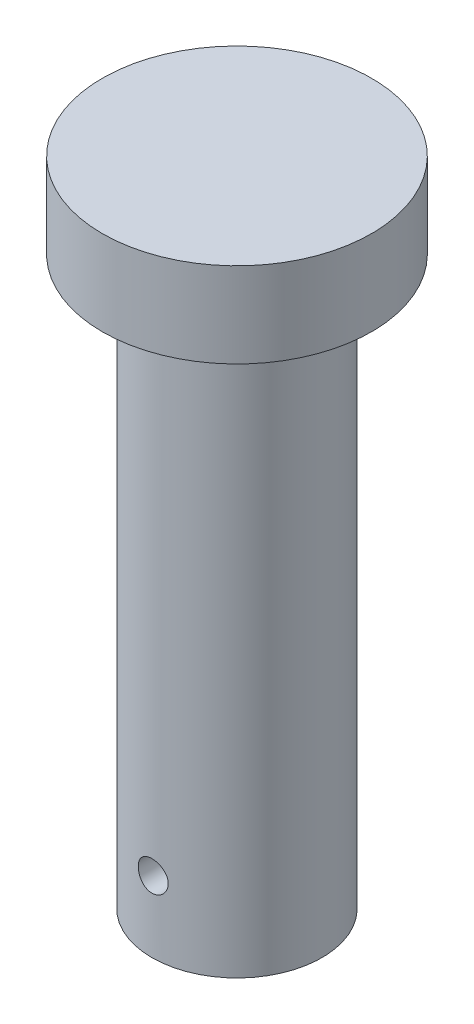
from build123d import *

# Parameters (mm, degrees)
SKETCH1_R           = 19
BOSS_EXTRUDE1_DEPTH = 12
SKETCH2_R           = 12
BOSS_EXTRUDE2_DEPTH = 80


with BuildPart() as part:
    # Sketch1 → Boss-Extrude1 (new body)
    with BuildSketch(Plane(origin=(0, 0, 0), x_dir=(1, 0, 0), z_dir=(0, 1, 0))):
        Circle(SKETCH1_R)
    extrude(amount=BOSS_EXTRUDE1_DEPTH)

    # Sketch2 → Boss-Extrude2 (add)
    with BuildSketch(Plane.XZ):
        Circle(SKETCH2_R)
    extrude(amount=BOSS_EXTRUDE2_DEPTH)

    # Sketch3 → Cut-Revolve1 (revolve, cut)
    with BuildSketch(Plane(origin=(0, -70, 0), x_dir=(-1, 0, 0), z_dir=(0, -1, 0))):
        Polygon((0, 22), (0, -22), (2, -22), (2.5, 22), align=None)
    revolve(axis=Axis((0, -70, -23.746840194), (0, 0, 1)), mode=Mode.SUBTRACT)


solid = part.part
